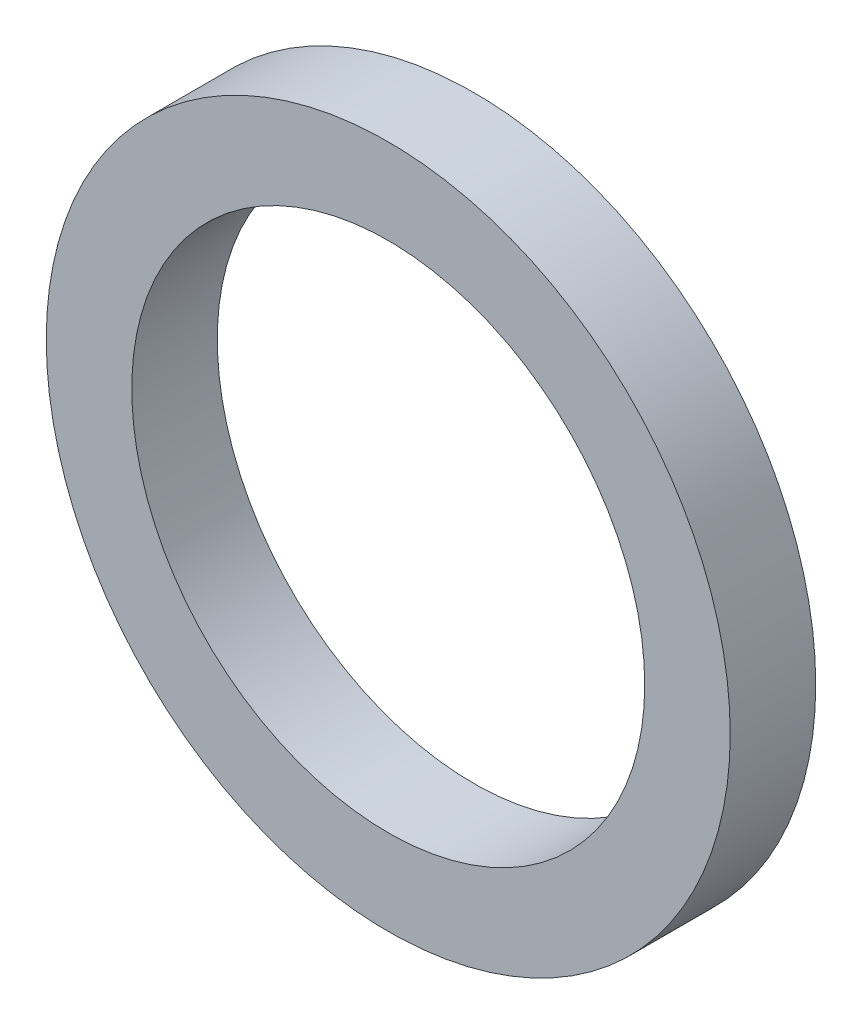
from build123d import *

# Parameters (mm, degrees)
CROQUIS1_R              = 4
CROQUIS1_R_2            = 3
SALIENTE_EXTRUIR1_DEPTH = 1


with BuildPart() as part:
    # Croquis1 → Saliente-Extruir1 (new body)
    with BuildSketch(Plane.XY):
        Circle(CROQUIS1_R)
        Circle(CROQUIS1_R_2, mode=Mode.SUBTRACT)
    extrude(amount=SALIENTE_EXTRUIR1_DEPTH)


solid = part.part
